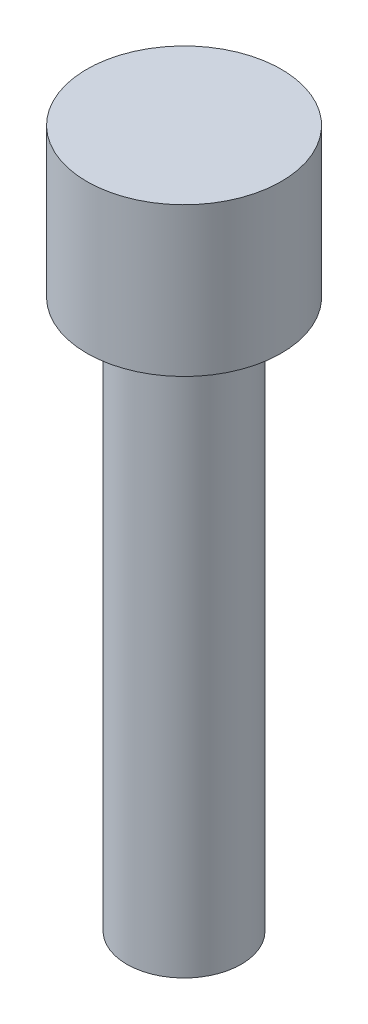
from build123d import *

# Parameters (mm, degrees)
SKETCH1_R           = 2.5
BOSS_EXTRUDE1_DEPTH = 24
SKETCH2_R           = 4.25
BOSS_EXTRUDE2_DEPTH = 6.5


with BuildPart() as part:
    # Sketch1 → Boss-Extrude1 (new body)
    with BuildSketch(Plane(origin=(0, 0, 0), x_dir=(1, 0, 0), z_dir=(0, 1, 0))):
        Circle(SKETCH1_R)
    extrude(amount=BOSS_EXTRUDE1_DEPTH)

    # Sketch2 → Boss-Extrude2 (add)
    with BuildSketch(Plane(origin=(0, 24, 0), x_dir=(1, 0, 0), z_dir=(0, 1, 0))):
        Circle(SKETCH2_R)
    extrude(amount=BOSS_EXTRUDE2_DEPTH)


solid = part.part
